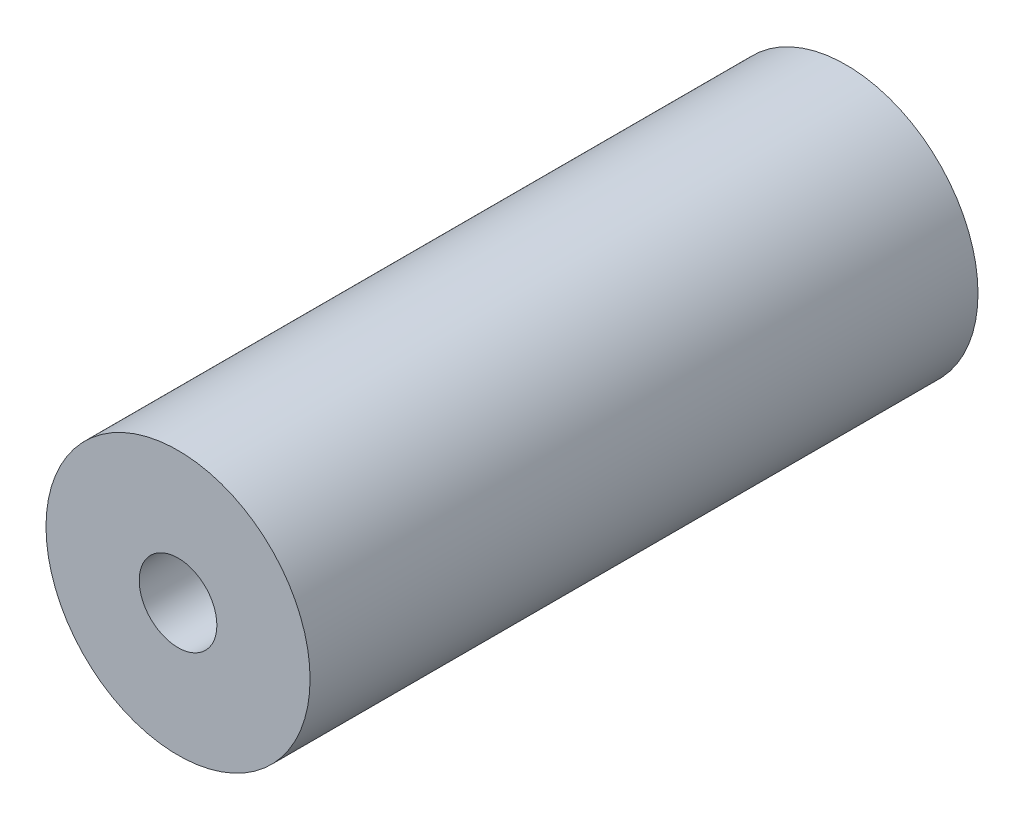
from build123d import *

# Parameters (mm, degrees)
CROQUIS1_R              = 17
CROQUIS1_R_2            = 5
SALIENTE_EXTRUIR1_DEPTH = 43


with BuildPart() as part:
    # Croquis1 → Saliente-Extruir1 (new body, symmetric)
    with BuildSketch(Plane.XY):
        Circle(CROQUIS1_R)
        Circle(CROQUIS1_R_2, mode=Mode.SUBTRACT)
    extrude(amount=SALIENTE_EXTRUIR1_DEPTH, both=True)


solid = part.part
